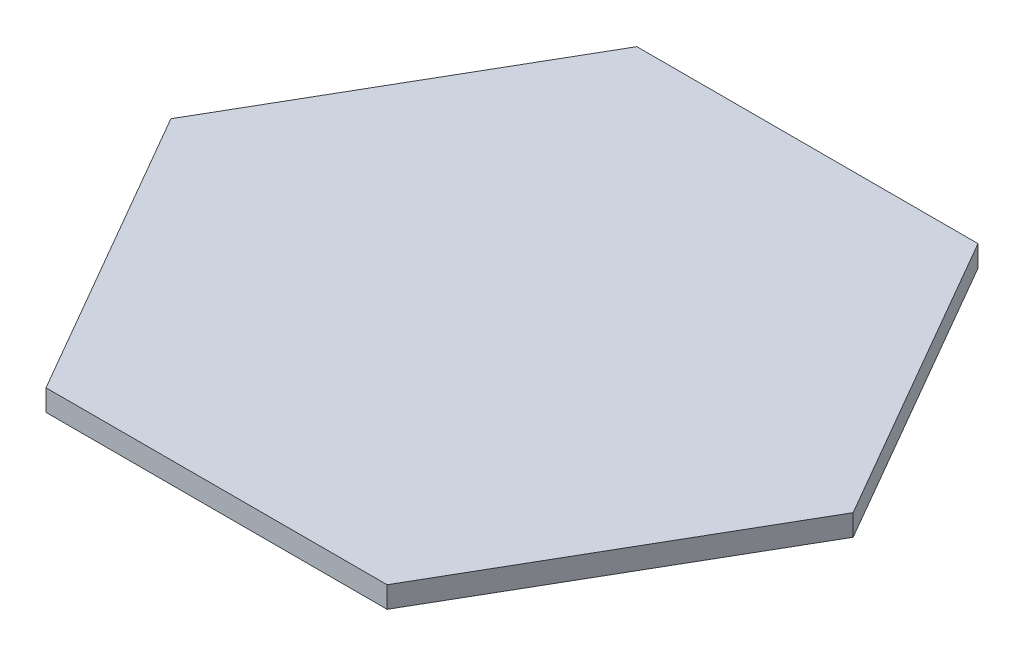
from build123d import *

# Parameters (mm, degrees)
BOSS_EXTRUDE1_DEPTH = 3.175


with BuildPart() as part:
    # Sketch1 → Boss-Extrude1 (new body)
    with BuildSketch(Plane(origin=(0, 0, 0), x_dir=(1, 0, 0), z_dir=(0, 1, 0))):
        Polygon((50.8, 0), (25.4, 43.994090512), (-25.4, 43.994090512), (-50.8, 0), (-25.4, -43.994090512), (25.4, -43.994090512), align=None)
    extrude(amount=BOSS_EXTRUDE1_DEPTH)


solid = part.part
